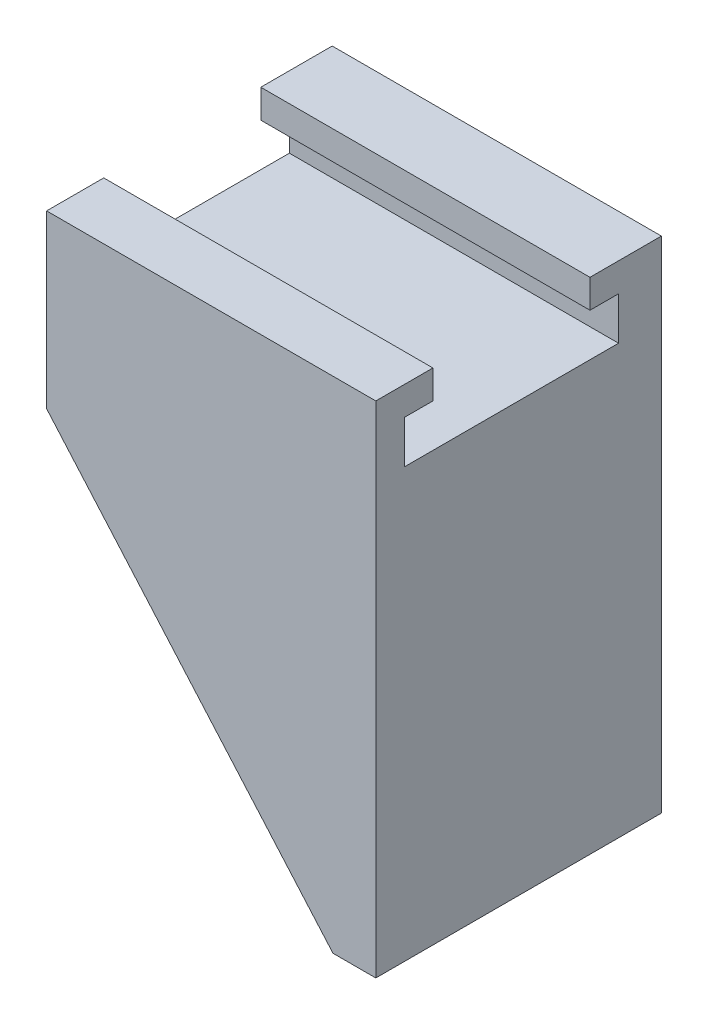
from build123d import *

# Parameters (mm, degrees)
BOSS_EXTRUDE1_DEPTH = 20
CUT_EXTRUDE1_DEPTH  = 24.053894737


with BuildPart() as part:
    # Sketch1 → Boss-Extrude1 (new body)
    with BuildSketch(Plane.XY):
        Polygon((-20.053894737, 23), (0, 0), (3, 0), (3, 35), (-20.053894737, 35), align=None)
    extrude(amount=BOSS_EXTRUDE1_DEPTH)

    # Sketch2 → Cut-Extrude1 (cut, through all)
    with BuildSketch(Plane(origin=(3, 0, 0), x_dir=(0, 0, -1), z_dir=(1, 0, 0))):
        Polygon((-5, 33), (-5, 35), (-16, 35), (-16, 33), (-18, 33), (-18, 30), (-3, 30), (-3, 33), align=None)
    extrude(amount=-CUT_EXTRUDE1_DEPTH, mode=Mode.SUBTRACT)


solid = part.part
